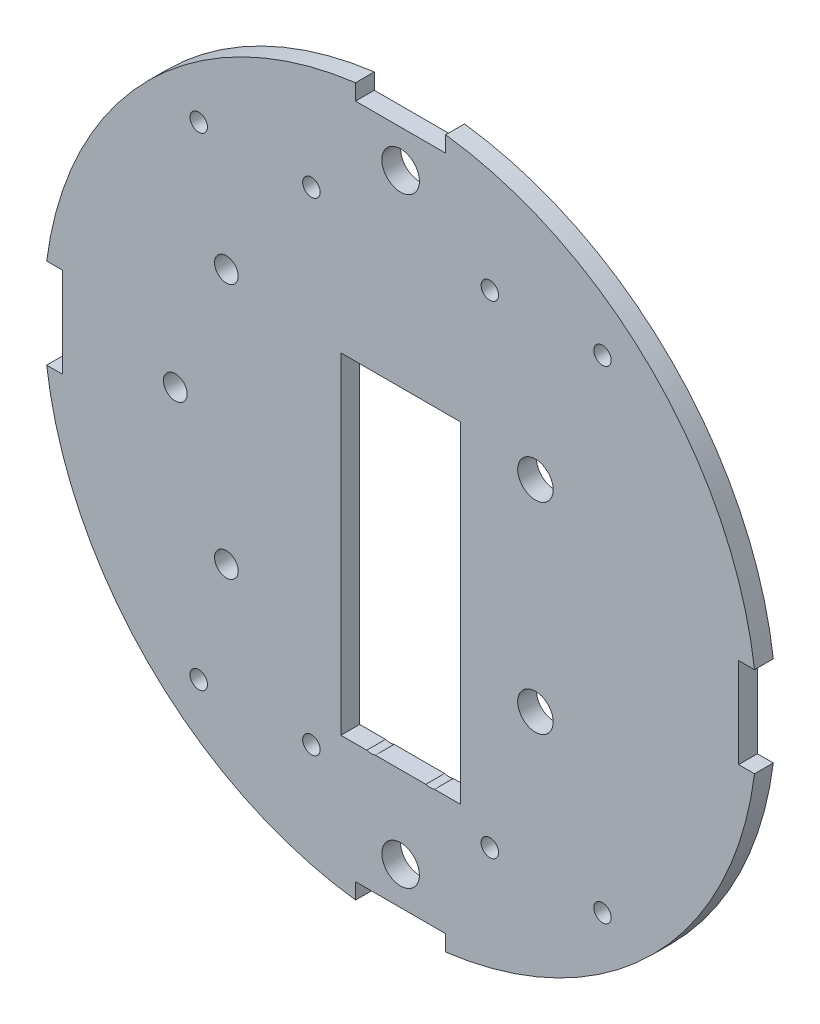
from build123d import *

# Parameters (mm, degrees)
SKETCH1_R           = 60.325
BOSS_EXTRUDE1_DEPTH = 3.175
SKETCH2_R           = 3.175
SKETCH2_W           = 15.24
SKETCH2_H           = 6.35
CUT_EXTRUDE1_DEPTH  = 3.175
CIRPATTERN1_COUNT   = 4
SKETCH3_R           = 2
SKETCH3_R_2         = 3
CUT_EXTRUDE2_DEPTH  = 3.175
SKETCH4_R           = 2.413
CUT_EXTRUDE3_DEPTH  = 3.175
SKETCH5_R           = 3.175
BOSS_EXTRUDE2_DEPTH = 3.175
SKETCH6_R           = 1.4732
CUT_EXTRUDE4_DEPTH  = 4.175


with BuildPart() as part:
    # Sketch1 → Boss-Extrude1 (new body)
    with BuildSketch(Plane.XY):
        Circle(SKETCH1_R)
    extrude(amount=BOSS_EXTRUDE1_DEPTH)

    # Sketch2 → Cut-Extrude1 (cut)
    with BuildSketch(Plane.XY.offset(3.175)):
        with Locations((0, 50.8)):
            Circle(SKETCH2_R)
        with Locations((0, 60.325)):
            Rectangle(SKETCH2_W, SKETCH2_H)
    cut_extrude1 = extrude(amount=-CUT_EXTRUDE1_DEPTH, mode=Mode.SUBTRACT)

    # CirPattern1: Cut-Extrude1 ×4 about axis
    cirpattern1_axis = Axis((0, 0, 0), (0, 0, 1))
    for i in range(1, CIRPATTERN1_COUNT):
        add(cut_extrude1.rotate(cirpattern1_axis, i * 360 / CIRPATTERN1_COUNT), mode=Mode.SUBTRACT)

    # Sketch3 → Cut-Extrude2 (cut)
    with BuildSketch(Plane.XY.offset(3.175)):
        with Locations((-38.1, 0)):
            Circle(SKETCH3_R)
        with Locations((-29.464, 21.59)):
            Circle(SKETCH3_R)
        with Locations((-29.464, -21.59)):
            Circle(SKETCH3_R)
        with Locations((22.8, 16.945239473)):
            Circle(SKETCH3_R_2)
        with Locations((22.8, -17.054760527)):
            Circle(SKETCH3_R_2)
        Polygon((-10.1, 19.05), (-10.1, -35.95), (-10.1, -36.95), (-9.1, -36.95), (9.1, -36.95), (10.1, -36.95), (10.1, -35.95), (10.1, 2.35), (10.1, 19.05), align=None)
    extrude(amount=-CUT_EXTRUDE2_DEPTH, mode=Mode.SUBTRACT)

    # Sketch4 → Cut-Extrude3 (cut)
    with BuildSketch(Plane(origin=(0, 0, 0), x_dir=(-1, 0, 0), z_dir=(0, 0, -1))):
        with Locations((5, -34.65)):
            Circle(SKETCH4_R)
        with Locations((-5, -34.65)):
            Circle(SKETCH4_R)
        with Locations((-5, 13.35)):
            Circle(SKETCH4_R)
        with Locations((5, 13.35)):
            Circle(SKETCH4_R)
    extrude(amount=-CUT_EXTRUDE3_DEPTH, mode=Mode.SUBTRACT)

    # Sketch5 → Boss-Extrude2 (add)
    with BuildSketch(Plane(origin=(0, 0, 0), x_dir=(-1, 0, 0), z_dir=(0, 0, -1))):
        with Locations((-50.8, 0)):
            Circle(SKETCH5_R)
        with Locations((50.8, 0)):
            Circle(SKETCH5_R)
    extrude(amount=-BOSS_EXTRUDE2_DEPTH)

    # Sketch6 → Cut-Extrude4 (cut, through all)
    with BuildSketch(Plane.XY.offset(3.175)):
        with Locations((15.084311186, 40.81189221)):
            Circle(SKETCH6_R)
        with Locations((34.134311186, 40.81189221)):
            Circle(SKETCH6_R)
        with Locations((34.134311186, -40.81189221)):
            Circle(SKETCH6_R)
        with Locations((15.084311186, -40.81189221)):
            Circle(SKETCH6_R)
        with Locations((-15.084311186, -40.81189221)):
            Circle(SKETCH6_R)
        with Locations((-34.134311186, -40.81189221)):
            Circle(SKETCH6_R)
        with Locations((-34.134311186, 40.81189221)):
            Circle(SKETCH6_R)
        with Locations((-15.084311186, 40.81189221)):
            Circle(SKETCH6_R)
    extrude(amount=-CUT_EXTRUDE4_DEPTH, mode=Mode.SUBTRACT)


solid = part.part
